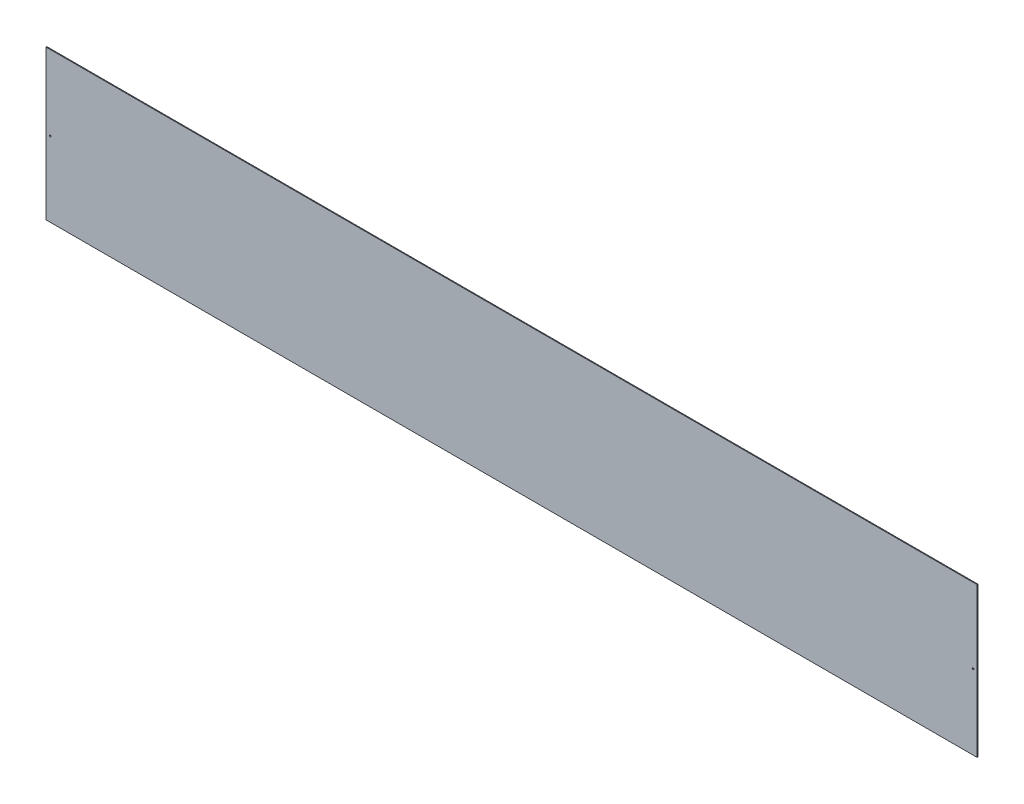
from build123d import *

# Parameters (mm, degrees)
SKETCH1_W           = 1120
SKETCH1_H           = 180
BOSS_EXTRUDE1_DEPTH = 1
SKETCH2_R           = 1
CUT_EXTRUDE1_DEPTH  = 2


with BuildPart() as part:
    # Sketch1 → Boss-Extrude1 (new body)
    with BuildSketch(Plane.XY):
        Rectangle(SKETCH1_W, SKETCH1_H)
    extrude(amount=BOSS_EXTRUDE1_DEPTH)

    # Sketch2 → Cut-Extrude1 (cut, through all)
    with BuildSketch(Plane(origin=(0, 0, 0), x_dir=(-1, 0, 0), z_dir=(0, 0, -1))):
        with Locations((-555, 0)):
            Circle(SKETCH2_R)
    cut_extrude1 = extrude(amount=-CUT_EXTRUDE1_DEPTH, mode=Mode.SUBTRACT)

    # Mirror1: Cut-Extrude1 across plane
    add(cut_extrude1.mirror(Plane(origin=(0, 0, 0), x_dir=(0, 0, 1), z_dir=(1, 0, 0))), mode=Mode.SUBTRACT)


solid = part.part
